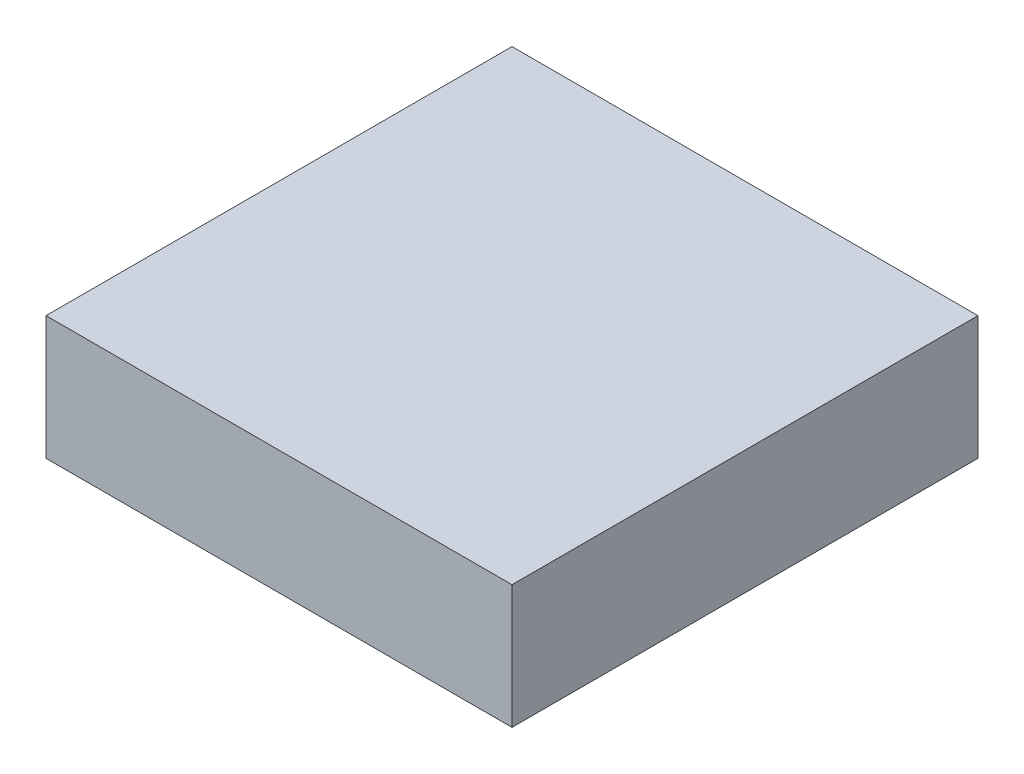
from build123d import *

# Parameters (mm, degrees)
SKETCH1_W      = 50
SKETCH1_H      = 50
EXTRUDE1_DEPTH = 6.63


with BuildPart() as part:
    # Sketch1 → Extrude1 (new body, symmetric)
    with BuildSketch(Plane(origin=(0, 0, 0), x_dir=(1, 0, 0), z_dir=(0, 1, 0))):
        Rectangle(SKETCH1_W, SKETCH1_H)
    extrude(amount=EXTRUDE1_DEPTH, both=True)


solid = part.part
